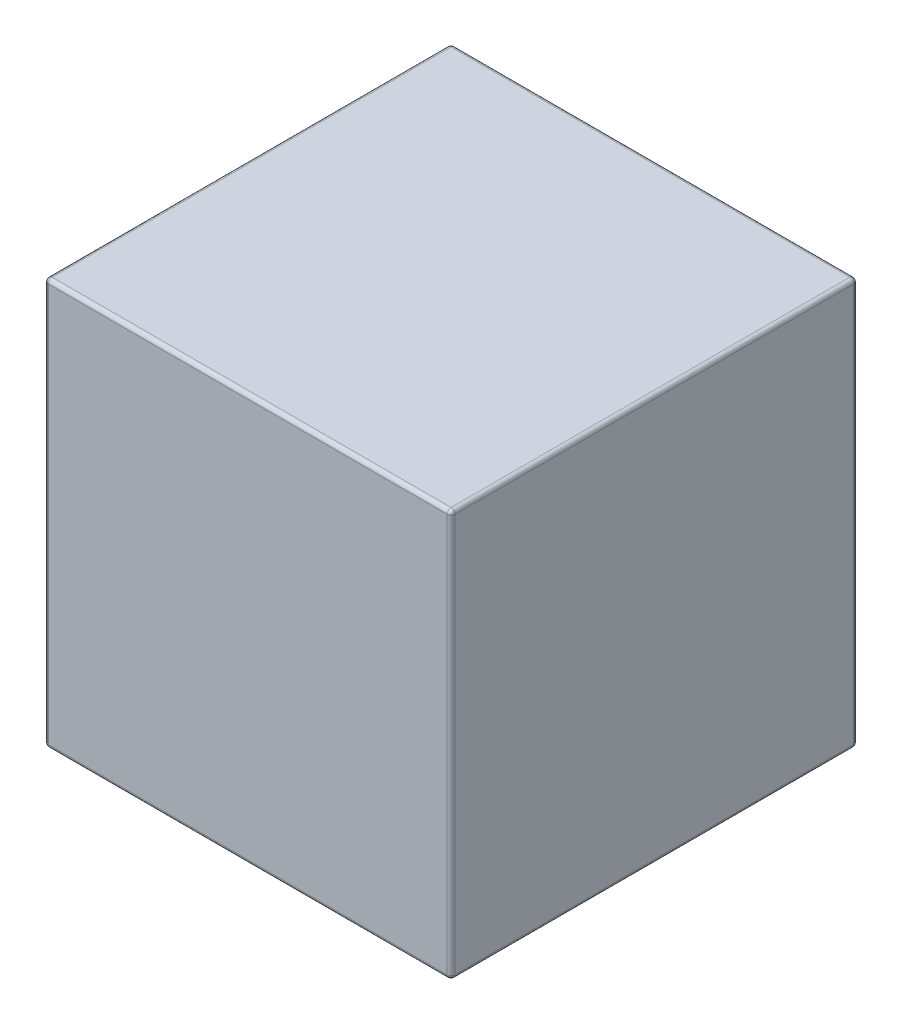
from build123d import *

# Parameters (mm, degrees)
SKETCH_1_W      = 52
SKETCH_1_H      = 52
EXTRUDE_1_DEPTH = 52
FILLET_1_R      = 0.5


with BuildPart() as part:
    # 草图1 → 凸台-拉伸1 (new body)
    with BuildSketch(Plane.XY):
        Rectangle(SKETCH_1_W, SKETCH_1_H)
    extrude(amount=EXTRUDE_1_DEPTH)

    # 圆角1
    fillet_1_edges = [part.edges().sort_by_distance(p)[0] for p in [
        (26, 0, 52),
        (0, 26, 52),
        (-26, 0, 52),
        (0, 26, 0),
        (26, 0, 0),
        (0, -26, 0),
        (-26, 0, 0),
        (0, -26, 52),
        (-26, 26, 26),
        (26, 26, 26),
        (26, -26, 26),
        (-26, -26, 26),
    ]]
    fillet(fillet_1_edges, radius=FILLET_1_R)


solid = part.part
